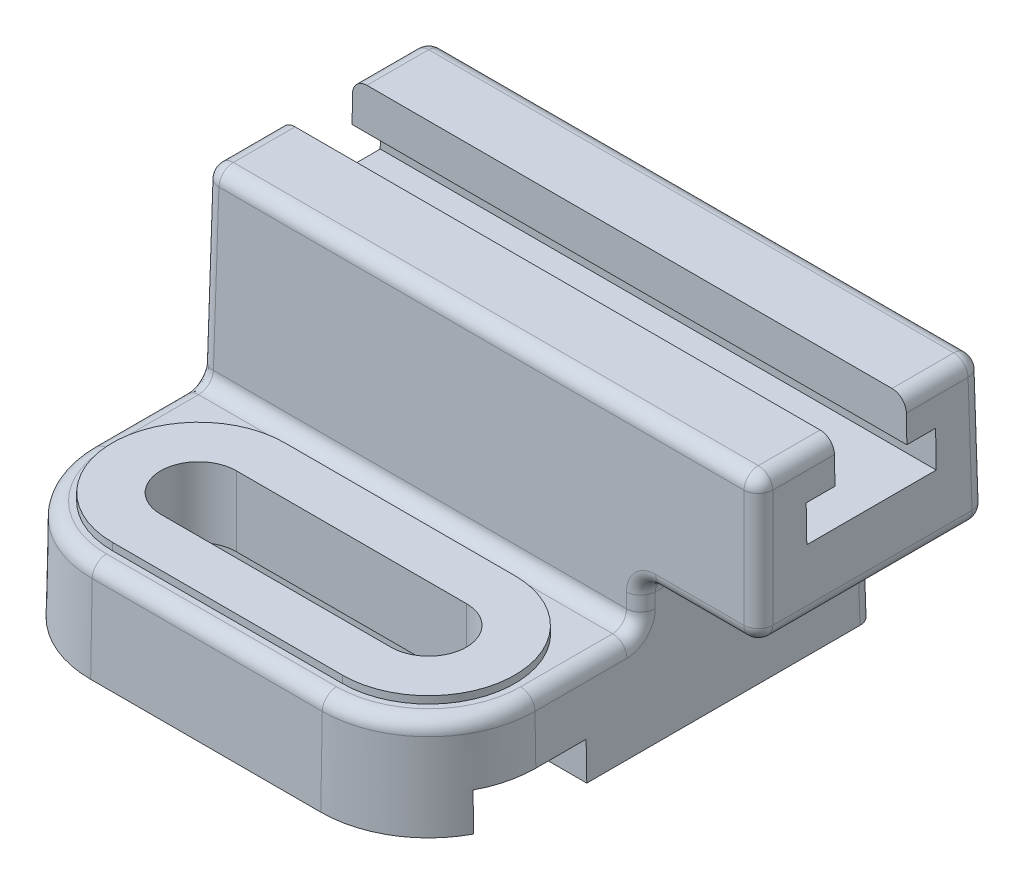
from build123d import *

# Parameters (mm, degrees)
BOSS_EXTRUDE4_DEPTH     = 22.225
BOSS_EXTRUDE4_TAPER     = 1
BOSS_EXTRUDE5_START     = 22.225
BOSS_EXTRUDE5_DEPTH     = 1.5875
BOSS_EXTRUDE5_TAPER     = 1
CUT_EXTRUDE4_DEPTH      = 24.8125001
SKETCH3_W               = 97.649122364
SKETCH3_H               = 50.8
BOSS_EXTRUDE6_DEPTH     = 9.525
BOSS_EXTRUDE6_TAPER     = 1
BOSS_EXTRUDE7_DEPTH     = 31.75
BOSS_EXTRUDE7_TAPER     = 1
SKETCH4_W               = 73.025
SKETCH4_H               = 30.94228
CUT_EXTRUDE1_DEPTH      = 36.5125
CUT_EXTRUDE1_TAPER      = 1
CUT_EXTRUDE2_DEPTH      = 75.6125001
CUT_EXTRUDE2_DEPTH_BACK = 50.2125001
FILLET1_R               = 3.175
CUT_EXTRUDE3_DEPTH      = 8.334375


with BuildPart() as part:
    # Sketch2 → Boss-Extrude4 (new body)
    with BuildSketch(Plane(origin=(0, 0, 0), x_dir=(1, 0, 0), z_dir=(0, 1, 0))):
        with BuildLine():
            Line((49.2125, 49.2125), (-49.2125, 49.2125))
            Line((-49.2125, 49.2125), (-49.2125, -25.4))
            ThreePointArc((-49.2125, -25.4), (-42.237980227, -42.237980227), (-25.4, -49.2125))
            Line((-25.4, -49.2125), (25.4, -49.2125))
            ThreePointArc((25.4, -49.2125), (42.237980227, -42.237980227), (49.2125, -25.4))
            Line((49.2125, -25.4), (49.2125, 49.2125))
        make_face()
    extrude(amount=BOSS_EXTRUDE4_DEPTH, taper=BOSS_EXTRUDE4_TAPER)

    # Sketch2_3 → Boss-Extrude5 (add)
    with BuildSketch(Plane(origin=(0, 0, 0), x_dir=(1, 0, 0), z_dir=(0, 1, 0)).offset(BOSS_EXTRUDE5_START)):
        with BuildLine():
            ThreePointArc((-25.4, -6.35), (-44.45, -25.4), (-25.4, -44.45))
            Line((-25.4, -44.45), (25.4, -44.45))
            ThreePointArc((25.4, -44.45), (44.45, -25.4), (25.4, -6.35))
            Line((25.4, -6.35), (-25.4, -6.35))
        make_face()
    extrude(amount=BOSS_EXTRUDE5_DEPTH, taper=BOSS_EXTRUDE5_TAPER)

    # Sketch8 → Cut-Extrude4 (cut, through all)
    with BuildSketch(Plane.XZ):
        with BuildLine():
            Line((-25.4, 33.734375), (25.4, 33.734375))
            ThreePointArc((25.4, 33.734375), (33.734375, 25.4), (25.4, 17.065625))
            Line((25.4, 17.065625), (-25.4, 17.065625))
            ThreePointArc((-25.4, 17.065625), (-33.734375, 25.4), (-25.4, 33.734375))
        make_face()
    extrude(amount=-CUT_EXTRUDE4_DEPTH, mode=Mode.SUBTRACT)

    # Sketch3 → Boss-Extrude6 (add)
    with BuildSketch(Plane(origin=(0, 22.225, 0), x_dir=(1, 0, 0), z_dir=(0, 1, 0))):
        with Locations((0, 23.424561182)):
            Rectangle(SKETCH3_W, SKETCH3_H)
    extrude(amount=BOSS_EXTRUDE6_DEPTH, taper=BOSS_EXTRUDE6_TAPER)

    # Sketch5 → Boss-Extrude7 (add)
    with BuildSketch(Plane(origin=(0, 31.75, 0), x_dir=(1, 0, 0), z_dir=(0, 1, 0))):
        Polygon((48.658301689, 48.658301689), (-48.658301689, 48.658301689), (-48.658301689, -1.809179325), (48.658301689, -1.809179325), (74.6125, -1.809179325), (74.6125, 48.658301689), align=None)
    extrude(amount=BOSS_EXTRUDE7_DEPTH, taper=BOSS_EXTRUDE7_TAPER)

    # Sketch4 → Cut-Extrude1 (cut)
    with BuildSketch(Plane.XZ):
        with Locations((0, -23.8125)):
            Rectangle(SKETCH4_W, SKETCH4_H)
    extrude(amount=-CUT_EXTRUDE1_DEPTH, taper=CUT_EXTRUDE1_TAPER, mode=Mode.SUBTRACT)

    # Sketch6 → Cut-Extrude2 (cut, two sides)
    with BuildSketch(Plane(origin=(0, 0, 0), x_dir=(0, 0, -1), z_dir=(1, 0, 0))) as cut_extrude2_sk:
        Polygon((37.712061182, 46.434375), (9.137061182, 46.434375), (9.137061182, 54.371875), (15.487061182, 54.371875), (15.487061182, 63.5), (31.362061182, 63.5), (31.362061182, 54.371875), (37.712061182, 54.371875), align=None)
    extrude(amount=CUT_EXTRUDE2_DEPTH, mode=Mode.SUBTRACT)
    extrude(cut_extrude2_sk.sketch, amount=-CUT_EXTRUDE2_DEPTH_BACK, mode=Mode.SUBTRACT)

    # Fillet1
    fillet1_edges = [part.edges().sort_by_distance(p)[0] for p in [
        (-48.658301689, 31.75, -48.658301689),
        (41.963666058, 22.225, 41.963666058),
        (48.935400844, 15.875, -48.935400844),
        (-41.963666058, 22.225, 41.963666058),
        (-48.824561182, 22.225, 13.687719409),
        (48.824561182, 22.225, 13.687719409),
        (0, 22.225, 1.975438818),
        (-48.46433228, 42.8625, 1.615209916),
        (48.741431435, 26.9875, 1.892309071),
        (48.658301689, 31.75, -23.424561182),
        (61.635400844, 31.75, 1.809179325),
        (74.6125, 31.75, -23.424561182),
        (74.335400844, 47.625, 1.532080169),
        (61.635400844, 31.75, -48.658301689),
        (74.335400844, 47.625, -48.381202533),
        (12.977099156, 63.5, -48.104103377),
        (-48.104103377, 63.5, -39.73308228),
        (12.977099156, 63.5, 1.254981013),
        (74.058301689, 63.5, -7.116040084),
        (0, 22.225, 48.824561182),
        (35.875171942, 36.5125, -23.8125),
        (36.193835971, 18.25625, -8.660024029),
        (0, 36.5125, -38.646311942),
        (36.193835971, 18.25625, -38.964975971),
        (-35.875171942, 36.5125, -23.8125),
        (-36.193835971, 18.25625, -38.964975971),
        (0, 36.5125, -8.978688058),
        (-36.193835971, 18.25625, -8.660024029),
        (-48.104103377, 63.5, -7.116040084),
        (74.058301689, 63.5, -39.73308228),
    ]]
    fillet(fillet1_edges, radius=FILLET1_R)

    # Sketch7 → Cut-Extrude3 (cut)
    with BuildSketch(Plane.XZ):
        with BuildLine():
            Line((-49.2125, 14.29385), (49.2125, 14.29385))
            Line((49.2125, 14.29385), (49.2125, 25.4))
            ThreePointArc((49.2125, 25.4), (48.515143019, 31.120604814), (46.46391674, 36.50615))
            Line((46.46391674, 36.50615), (-46.46391674, 36.50615))
            ThreePointArc((-46.46391674, 36.50615), (-48.515143019, 31.120604814), (-49.2125, 25.4))
            Line((-49.2125, 25.4), (-49.2125, 14.29385))
        make_face()
        with BuildLine():
            Line((25.4, 17.065625), (-25.4, 17.065625))
            ThreePointArc((-25.4, 17.065625), (-33.734375, 25.4), (-25.4, 33.734375))
            Line((-25.4, 33.734375), (25.4, 33.734375))
            ThreePointArc((25.4, 33.734375), (33.734375, 25.4), (25.4, 17.065625))
        make_face(mode=Mode.SUBTRACT)
    extrude(amount=-CUT_EXTRUDE3_DEPTH, mode=Mode.SUBTRACT)


solid = part.part
